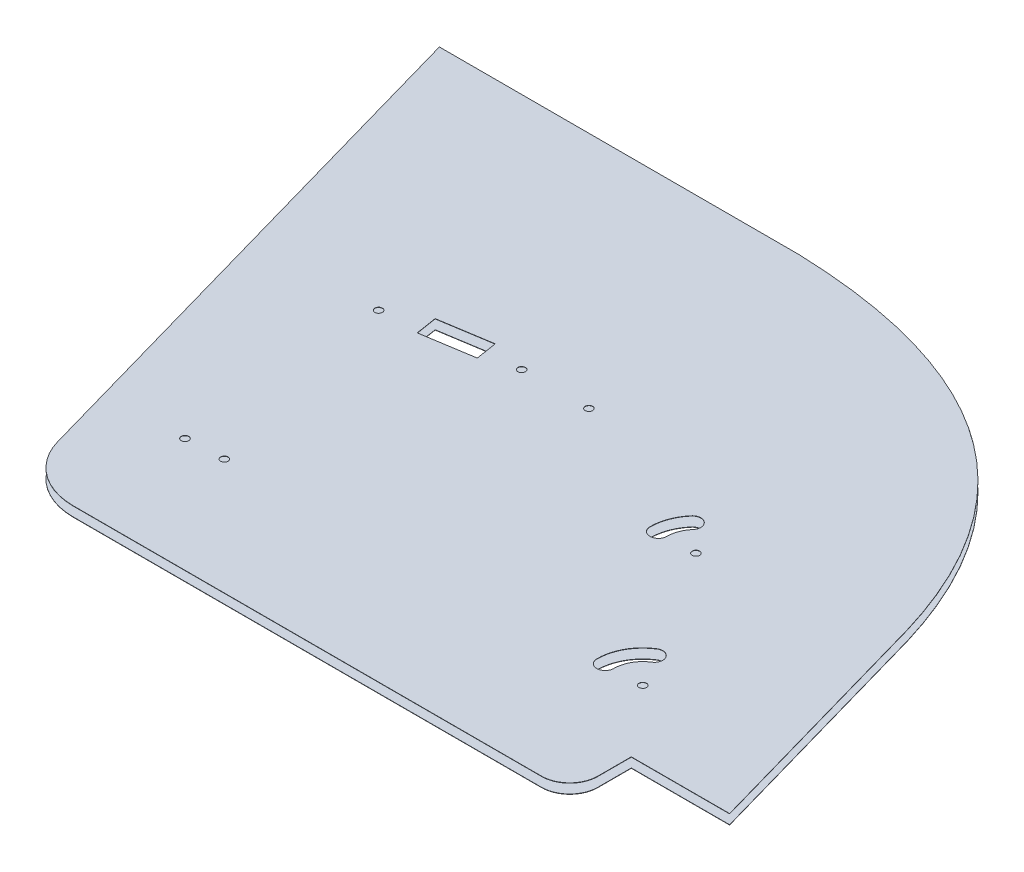
from build123d import *

# Parameters (mm, degrees)
DODANIE_WYCI_GNI_CIE1_DEPTH = 0.3
SZKIC3_R                    = 4
WYTNIJ_WYCI_GNI_CIE1_DEPTH  = 40
WYTNIJ_WYCI_GNI_CIE2_DEPTH  = 958.139765163


with BuildPart() as part:
    # Szkic1 → Dodanie-wyciągnięcie1 (new body)
    with BuildSketch(Plane.XZ.offset(-445)):
        with BuildLine():
            Line((-783.436356075, -69.14931872), (-400.038066875, -69.14931873))
            add(Edge.make_bspline(
                [(-400.038066875, -69.14931873), (-79.065173683, -58.88529232), (4.157071393, 219.238816637)],
                knots=[0, 0, 0, 1, 1, 1], degree=2))
            Line((4.157071393, 219.238816637), (79.223413624, 484.054193396))
            Line((79.223413624, 484.054193396), (-25.590426412, 484.054193396))
            Line((-25.590426412, 484.054193396), (-25.590426412, 519.755987478))
            ThreePointArc((-25.590426412, 519.755987478), (-34.377222976, 540.969190913), (-55.590426412, 549.755987478))
            Line((-55.590426412, 549.755987478), (-555.081943572, 549.755987478))
            ThreePointArc((-555.081943572, 549.755987478), (-597.293703671, 535.596540029), (-622.42845809, 498.846482029))
            Line((-622.42845809, 498.846482029), (-783.436356075, -69.14931872))
        make_face()
    extrude(amount=DODANIE_WYCI_GNI_CIE1_DEPTH)


with BuildPart() as body_2:
    # Lustro2: mirrored copy
    add(part.part.mirror(Plane.ZX.offset(450)))


with BuildPart() as wytnij_wyci_gni_cie1_tool:
    # Szkic3 → Wytnij-wyciągnięcie1 (new body)
    with BuildSketch(Plane.XZ.offset(-444.7)):
        with Locations(Location((-572.687982615, 206.365683115, 0), (0, 0, 270))):
            Circle(SZKIC3_R)
        with Locations(Location((-441.66371711, 184.906368669, 0), (0, 0, 270))):
            Circle(SZKIC3_R)
        with Locations(Location((-369.907883248, 184.906368669, 0), (0, 0, 270))):
            Circle(SZKIC3_R)
        with Locations(Location((-557.500474948, 428.076305614, 0), (0, 0, 270))):
            Circle(SZKIC3_R)
        with Locations(Location((-517.500474948, 426.079306347, 0), (0, 0, 270))):
            Circle(SZKIC3_R)
        with Locations(Location((-179.166238959, 261.544556892, 0), (0, 0, 270))):
            Circle(SZKIC3_R)
        with Locations(Location((-85.513533731, 411.920534849, 0), (0, 0, 270))):
            Circle(SZKIC3_R)
        Polygon((-524.320658323, 205.601886031), (-482.837748018, 199.031638499), (-486.435740714, 176.314806666), (-527.918651019, 182.885054197), align=None)
        with BuildLine():
            ThreePointArc((-116.513533731, 411.920534849), (-112.677886877, 396.984072143), (-102.120119655, 385.743802739))
            ThreePointArc((-102.120119655, 385.743802739), (-99.341690118, 373.322839439), (-111.762653418, 370.544409902))
            ThreePointArc((-111.762653418, 370.544409902), (-128.45073709, 388.311287346), (-134.513533731, 411.920534849))
            ThreePointArc((-134.513533731, 411.920534849), (-125.513533731, 420.920534849), (-116.513533731, 411.920534849))
        make_face()
        with BuildLine():
            ThreePointArc((-210.166238959, 261.544556892), (-208.190571246, 250.654738927), (-202.51539152, 241.152963656))
            ThreePointArc((-202.51539152, 241.152963656), (-203.374037775, 228.454037457), (-216.072963974, 229.312683713))
            ThreePointArc((-216.072963974, 229.312683713), (-225.043409348, 244.331618818), (-228.166238959, 261.544556892))
            ThreePointArc((-228.166238959, 261.544556892), (-219.166238959, 270.544556892), (-210.166238959, 261.544556892))
        make_face()
    extrude(amount=-WYTNIJ_WYCI_GNI_CIE1_DEPTH)


with BuildPart() as part_1:
    add(part.part)

    # Wytnij-wyciągnięcie1: cut by wytnij_wyci_gni_cie1_tool
    add(wytnij_wyci_gni_cie1_tool.part, mode=Mode.SUBTRACT)


with BuildPart() as body_2_1:
    add(body_2.part)

    # Wytnij-wyciągnięcie1: cut by wytnij_wyci_gni_cie1_tool
    add(wytnij_wyci_gni_cie1_tool.part, mode=Mode.SUBTRACT)


with BuildPart() as wytnij_wyci_gni_cie2_tool:
    # Szkic4 → Wytnij-wyciągnięcie2 (new, through all)
    with BuildSketch(Plane(origin=(0, 455.3, 0), x_dir=(1, 0, 0), z_dir=(0, 1, 0))):
        Polygon((-527.918651019, -182.885054197), (-486.435740714, -176.314806666), (-479.52192233, -175.21976541), (-475.923929634, -197.936597244), (-482.837748018, -199.031638499), (-531.234476707, -206.696927286), (-534.832469403, -183.980095453), align=None)
    extrude(amount=-WYTNIJ_WYCI_GNI_CIE2_DEPTH)


with BuildPart() as part_2:
    add(part_1.part)

    # Wytnij-wyciągnięcie2: cut by wytnij_wyci_gni_cie2_tool
    add(wytnij_wyci_gni_cie2_tool.part, mode=Mode.SUBTRACT)


with BuildPart() as body_2_2:
    add(body_2_1.part)

    # Wytnij-wyciągnięcie2: cut by wytnij_wyci_gni_cie2_tool
    add(wytnij_wyci_gni_cie2_tool.part, mode=Mode.SUBTRACT)


solid = Compound([part_2.part, body_2_2.part])
